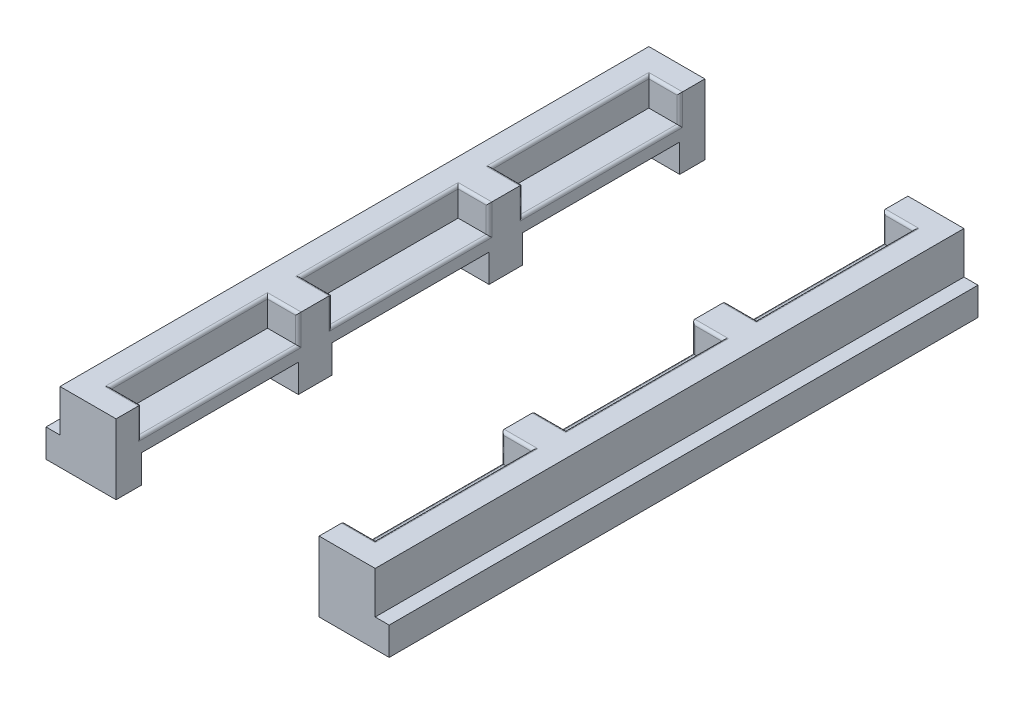
from build123d import *

# Parameters (mm, degrees)
SKIZZE1_W                       = 140
SKIZZE1_H                       = 210
AUFSATZ_LINEAR_AUSTRAGEN1_DEPTH = 2
SKIZZE2_W                       = 20
SKIZZE2_H                       = 210
AUFSATZ_LINEAR_AUSTRAGEN2_DEPTH = 15
SKIZZE3_W                       = 94.4
SKIZZE3_H                       = 56
SCHNITT_LINEAR_AUSTRAGEN1_DEPTH = 10
VERRUNDUNG1_R                   = 1
SKIZZE4_W                       = 140
SKIZZE4_H                       = 210
SCHNITT_LINEAR_AUSTRAGEN2_DEPTH = 2
SKIZZE7_W                       = 25
SKIZZE7_H                       = 210
AUFSATZ_LINEAR_AUSTRAGEN3_DEPTH = 10
SKIZZE5_W                       = 110.4
SKIZZE5_H                       = 56
SCHNITT_LINEAR_AUSTRAGEN3_DEPTH = 10


with BuildPart() as part:
    # Skizze1 → Aufsatz-Linear austragen1 (new body)
    with BuildSketch(Plane(origin=(0, 0, 0), x_dir=(1, 0, 0), z_dir=(0, 1, 0))):
        Rectangle(SKIZZE1_W, SKIZZE1_H)
    extrude(amount=AUFSATZ_LINEAR_AUSTRAGEN1_DEPTH)

    # Skizze2 → Aufsatz-Linear austragen2 (add)
    with BuildSketch(Plane(origin=(0, 2, 0), x_dir=(1, 0, 0), z_dir=(0, 1, 0))):
        with Locations((-46.2, 0)):
            Rectangle(SKIZZE2_W, SKIZZE2_H)
        with Locations((46.2, 0)):
            Rectangle(SKIZZE2_W, SKIZZE2_H)
    extrude(amount=AUFSATZ_LINEAR_AUSTRAGEN2_DEPTH)

    # Skizze3 → Schnitt-Linear austragen1 (cut)
    with BuildSketch(Plane(origin=(0, 17, 0), x_dir=(1, 0, 0), z_dir=(0, 1, 0))):
        Rectangle(SKIZZE3_W, SKIZZE3_H)
        with Locations((0, -68)):
            Rectangle(SKIZZE3_W, SKIZZE3_H)
        with Locations((0, 68)):
            Rectangle(SKIZZE3_W, SKIZZE3_H)
    extrude(amount=-SCHNITT_LINEAR_AUSTRAGEN1_DEPTH, mode=Mode.SUBTRACT)

    # Verrundung1
    verrundung1_edges = [part.edges().sort_by_distance(p)[0] for p in [
        (41.7, 17, 28),
        (41.7, 17, -40),
        (41.7, 17, 96),
        (36.2, 7, 0),
        (36.2, 7, -68),
        (36.2, 7, 68),
        (-36.2, 7, 68),
        (-41.7, 17, 40),
        (-47.2, 17, 68),
        (-41.7, 17, 96),
        (47.2, 17, 68),
        (41.7, 17, 40),
        (-36.2, 12, 96),
        (36.2, 12, 96),
        (-36.2, 12, 40),
        (36.2, 12, 40),
        (-36.2, 7, -68),
        (-41.7, 17, -96),
        (-47.2, 17, -68),
        (-41.7, 17, -40),
        (47.2, 17, -68),
        (41.7, 17, -96),
        (-36.2, 12, -40),
        (36.2, 12, -40),
        (-36.2, 12, -96),
        (36.2, 12, -96),
        (-36.2, 7, 0),
        (-41.7, 17, -28),
        (-47.2, 17, 0),
        (-41.7, 17, 28),
        (47.2, 17, 0),
        (41.7, 17, -28),
        (-36.2, 12, 28),
        (36.2, 12, 28),
        (-36.2, 12, -28),
        (36.2, 12, -28),
    ]]
    fillet(verrundung1_edges, radius=VERRUNDUNG1_R)

    # Skizze4 → Schnitt-Linear austragen2 (cut)
    with BuildSketch(Plane.XZ):
        Rectangle(SKIZZE4_W, SKIZZE4_H)
    extrude(amount=-SCHNITT_LINEAR_AUSTRAGEN2_DEPTH, mode=Mode.SUBTRACT)

    # Skizze7 → Aufsatz-Linear austragen3 (add)
    with BuildSketch(Plane.XZ.offset(-2)):
        with Locations((-48.7, 0)):
            Rectangle(SKIZZE7_W, SKIZZE7_H)
        with Locations((48.7, 0)):
            Rectangle(SKIZZE7_W, SKIZZE7_H)
    extrude(amount=AUFSATZ_LINEAR_AUSTRAGEN3_DEPTH)

    # Skizze5 → Schnitt-Linear austragen3 (cut)
    with BuildSketch(Plane.XZ.offset(8)):
        Rectangle(SKIZZE5_W, SKIZZE5_H)
        with Locations((0, -68)):
            Rectangle(SKIZZE5_W, SKIZZE5_H)
        with Locations((0, 68)):
            Rectangle(SKIZZE5_W, SKIZZE5_H)
    extrude(amount=-SCHNITT_LINEAR_AUSTRAGEN3_DEPTH, mode=Mode.SUBTRACT)


solid = part.part
